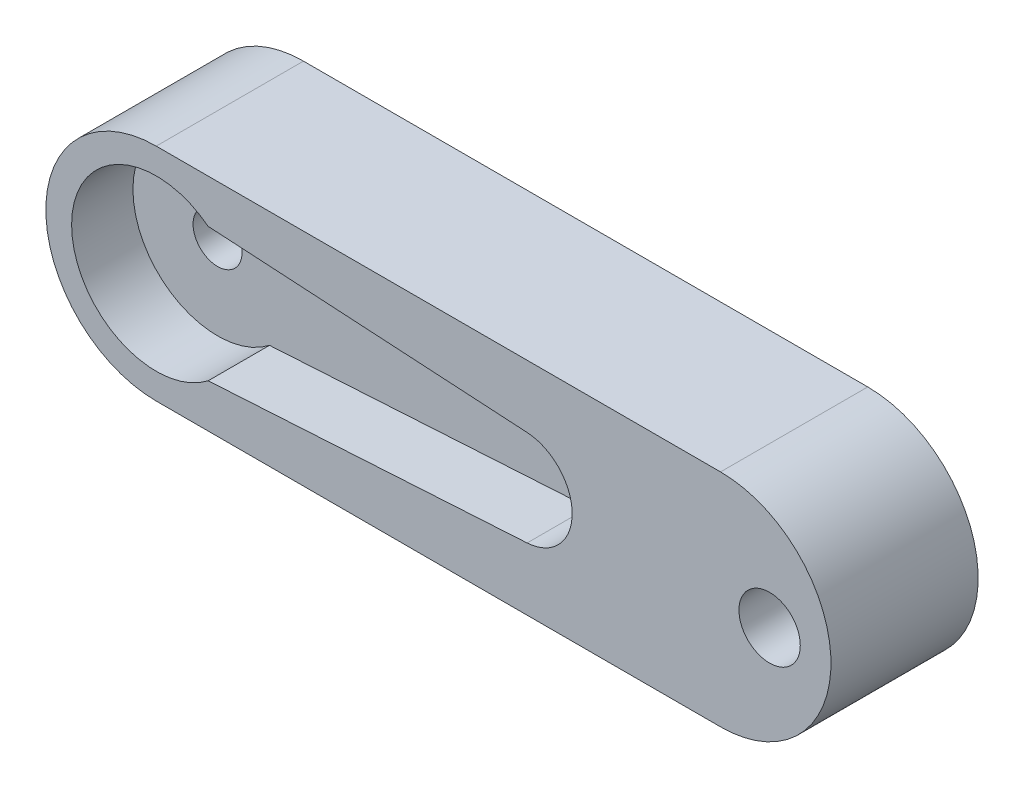
from build123d import *

# Parameters (mm, degrees)
BOSS_EXTRUDE1_DEPTH = 6
CUT_EXTRUDE1_DEPTH  = 2.5
SKETCH3_R           = 1
CUT_EXTRUDE2_DEPTH  = 7
SKETCH4_R           = 2
CUT_EXTRUDE3_DEPTH  = 1.5
SKETCH5_R           = 1.25
CUT_EXTRUDE4_DEPTH  = 7


with BuildPart() as part:
    # Sketch1 → Boss-Extrude1 (new body)
    with BuildSketch(Plane.XY):
        with BuildLine():
            Line((0, 4.5), (23, 4.5))
            ThreePointArc((23, 4.5), (27.5, 0), (23, -4.5))
            Line((23, -4.5), (0, -4.5))
            ThreePointArc((0, -4.5), (-4.5, 0), (0, 4.5))
        make_face()
    extrude(amount=BOSS_EXTRUDE1_DEPTH)

    # Sketch2 → Cut-Extrude1 (cut)
    with BuildSketch(Plane.XY.offset(6)):
        with BuildLine():
            Line((2.115862708, 2.725), (15.116246568, 1.95))
            ThreePointArc((15.116246568, 1.95), (16.953461867, 0), (15.116246568, -1.95))
            Line((15.116246568, -1.95), (2.115862708, -2.725))
            ThreePointArc((2.115862708, -2.725), (-3.45, 0), (2.115862708, 2.725))
        make_face()
    extrude(amount=-CUT_EXTRUDE1_DEPTH, mode=Mode.SUBTRACT)

    # Sketch3 → Cut-Extrude2 (cut, through all)
    with BuildSketch(Plane.XY.offset(6)):
        Circle(SKETCH3_R)
    extrude(amount=-CUT_EXTRUDE2_DEPTH, mode=Mode.SUBTRACT)

    # Sketch4 → Cut-Extrude3 (cut)
    with BuildSketch(Plane(origin=(0, 0, 0), x_dir=(-1, 0, 0), z_dir=(0, 0, -1))):
        Circle(SKETCH4_R)
    extrude(amount=-CUT_EXTRUDE3_DEPTH, mode=Mode.SUBTRACT)

    # Sketch5 → Cut-Extrude4 (cut, through all)
    with BuildSketch(Plane.XY.offset(6)):
        with Locations((25, 0)):
            Circle(SKETCH5_R)
    extrude(amount=-CUT_EXTRUDE4_DEPTH, mode=Mode.SUBTRACT)


solid = part.part
